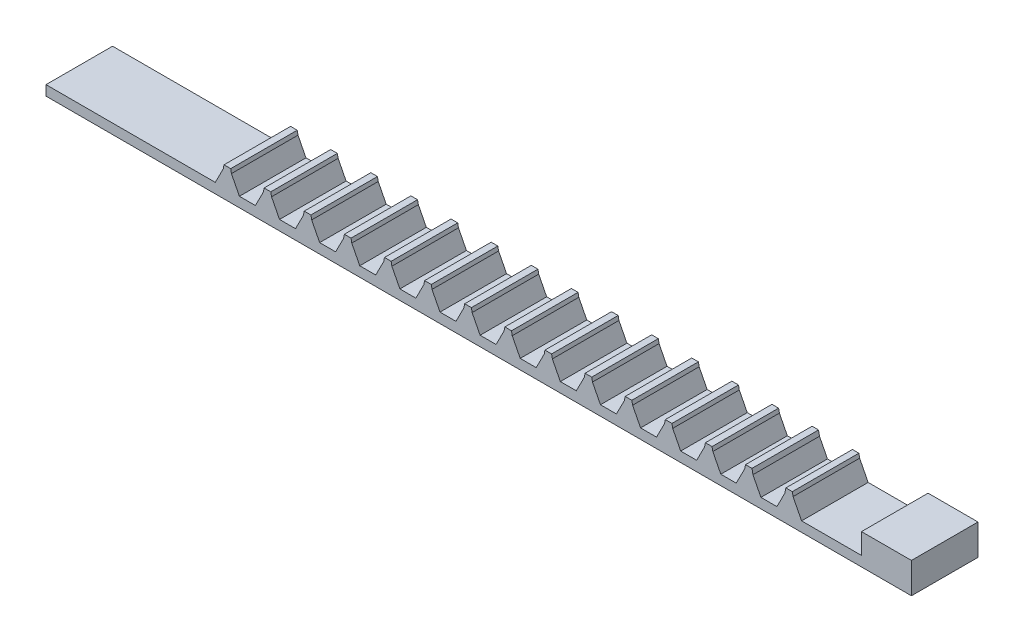
from build123d import *

# Parameters (mm, degrees)
SKETCH1_W           = 66.04
SKETCH1_H           = 5.08
BOSS_EXTRUDE1_DEPTH = 3.81
SKETCH2_W           = 4.572
SKETCH2_H           = 3.048
CUT_EXTRUDE1_DEPTH  = 6.08
CHAMFER1_SIZE       = 0.254
CUT_EXTRUDE2_DEPTH  = 6.08
SKETCH5_W           = 12.916630293
SKETCH5_H           = 3.048
CUT_EXTRUDE3_DEPTH  = 6.08
SKETCH6_W           = 3.81
SKETCH6_H           = 1.726747829
CUT_EXTRUDE4_DEPTH  = 6.08


with BuildPart() as part:
    # Sketch1 → Boss-Extrude1 (new body)
    with BuildSketch(Plane(origin=(0, 0, 0), x_dir=(1, 0, 0), z_dir=(0, 1, 0))):
        with Locations((-87.329253942, 35.396987703)):
            Rectangle(SKETCH1_W, SKETCH1_H)
    extrude(amount=BOSS_EXTRUDE1_DEPTH)

    # Sketch2 → Cut-Extrude1 (cut, through all)
    with BuildSketch(Plane.XY.offset(-32.856987703)):
        with Locations((-60.405253942, 2.286)):
            Rectangle(SKETCH2_W, SKETCH2_H)
    extrude(amount=-CUT_EXTRUDE1_DEPTH, mode=Mode.SUBTRACT)

    # Chamfer1
    chamfer1_edges = [part.edges().sort_by_distance(p)[0] for p in [
        (-54.309253942, 3.81, -35.396987703),
        (-58.119253942, 3.81, -35.396987703),
    ]]
    chamfer(chamfer1_edges, length=CHAMFER1_SIZE)

    # Sketch4 → Cut-Extrude2 (cut, through all)
    with BuildSketch(Plane.XY.offset(-32.856987703)):
        Polygon((-64.575422666, 0.762), (-65.794622666, 0.762), (-66.403478406, 1.95694667), (-66.477713127, 2.338851205), (-66.969636987, 2.338851205), (-67.027795569, 2.03965124), (-67.678791391, 0.762), (-68.855851308, 0.762), (-69.464707047, 1.95694667), (-69.522865629, 2.256146635), (-70.030865629, 2.256146635), (-70.089024211, 1.95694667), (-70.69787995, 0.762), (-71.91707995, 0.762), (-72.525935689, 1.95694667), (-72.584094271, 2.256146635), (-73.092094271, 2.256146635), (-73.150252852, 1.95694667), (-73.759108591, 0.762), (-74.978308591, 0.762), (-75.58716433, 1.95694667), (-75.645322912, 2.256146635), (-76.153322912, 2.256146635), (-76.211481494, 1.95694667), (-76.820337233, 0.762), (-78.039537233, 0.762), (-78.648392972, 1.95694667), (-78.706551554, 2.256146635), (-79.214551554, 2.256146635), (-79.272710136, 1.95694667), (-79.881565875, 0.762), (-81.100765875, 0.762), (-81.709621614, 1.95694667), (-81.767780195, 2.256146635), (-82.275780195, 2.256146635), (-82.333938777, 1.95694667), (-82.942794516, 0.762), (-84.161994516, 0.762), (-84.770850255, 1.95694667), (-84.829008837, 2.256146635), (-85.337008837, 2.256146635), (-85.395167419, 1.95694667), (-86.004023158, 0.762), (-87.223223158, 0.762), (-87.832078897, 1.95694667), (-87.890237479, 2.256146635), (-88.398237479, 2.256146635), (-88.45639606, 1.95694667), (-89.065251799, 0.762), (-90.284451799, 0.762), (-90.893307538, 1.95694667), (-90.95146612, 2.256146635), (-91.45946612, 2.256146635), (-91.517624702, 1.95694667), (-92.126480441, 0.762), (-93.345680441, 0.762), (-93.95453618, 1.95694667), (-94.012694762, 2.256146635), (-94.520694762, 2.256146635), (-94.578853344, 1.95694667), (-95.187709083, 0.762), (-96.406909083, 0.762), (-97.015764822, 1.95694667), (-97.073923403, 2.256146635), (-97.581923403, 2.256146635), (-97.640081985, 1.95694667), (-98.248937724, 0.762), (-99.468137724, 0.762), (-100.076993463, 1.95694667), (-100.135152045, 2.256146635), (-100.643152045, 2.256146635), (-100.701310627, 1.95694667), (-101.310166366, 0.762), (-102.529366366, 0.762), (-103.138222105, 1.95694667), (-103.196380687, 2.256146635), (-103.704380687, 2.256146635), (-103.762539268, 1.95694667), (-104.371395007, 0.762), (-105.590595007, 0.762), (-106.199450746, 1.95694667), (-106.257609328, 2.256146635), (-106.765609328, 2.256146635), (-106.82376791, 1.95694667), (-107.432623649, 0.762), (-107.432623649, 3.81), (-106.257609328, 3.81), (-62.691253942, 3.81), (-62.691253942, 0.762), (-63.342249764, 2.03965124), (-63.400408346, 2.338851205), (-63.892332206, 2.338851205), (-63.966566927, 1.95694667), align=None)
    extrude(amount=-CUT_EXTRUDE2_DEPTH, mode=Mode.SUBTRACT)

    # Sketch5 → Cut-Extrude3 (cut, through all)
    with BuildSketch(Plane.XY.offset(-32.856987703)):
        with Locations((-113.890938796, 2.286)):
            Rectangle(SKETCH5_W, SKETCH5_H)
    extrude(amount=-CUT_EXTRUDE3_DEPTH, mode=Mode.SUBTRACT)

    # Sketch6 → Cut-Extrude4 (cut, through all)
    with BuildSketch(Plane.XY.offset(-32.856987703)):
        with Locations((-56.214253942, 3.202225119)):
            Rectangle(SKETCH6_W, SKETCH6_H)
    extrude(amount=-CUT_EXTRUDE4_DEPTH, mode=Mode.SUBTRACT)


solid = part.part
